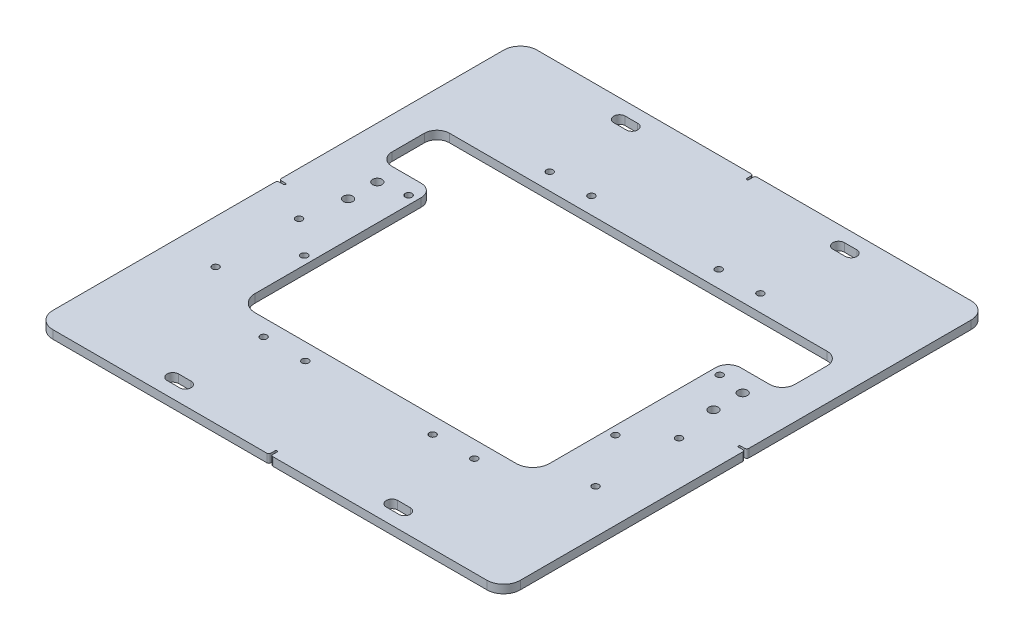
from build123d import *

# Parameters (mm, degrees)
SKETCH2_W               = 355.6
SKETCH2_H               = 368.3
BOSS_EXTRUDE1_DEPTH     = 6.35
FILLET1_R               = 12.7
MOUNTING_HOLES_DEPTH    = 7.35
PLUNGER_CUTOUT_DEPTH    = 7.35
F_1_4_20_TAPPED_HOLE2_D = 5.1054
CENTERING_MARKERS_DEPTH = 7.35
FILLET2_R               = 1.5875
F_1_4_20_TAPPED_HOLE5_D = 5.1054
SKETCH17_R              = 3.571875
CUT_EXTRUDE1_DEPTH      = 7.35


with BuildPart() as part:
    # Sketch2 → Boss-Extrude1 (new body)
    with BuildSketch(Plane(origin=(0, 0, 0), x_dir=(1, 0, 0), z_dir=(0, 1, 0))):
        Rectangle(SKETCH2_W, SKETCH2_H)
    extrude(amount=BOSS_EXTRUDE1_DEPTH)

    # Fillet1
    fillet1_edges = [part.edges().sort_by_distance(p)[0] for p in [
        (177.8, 3.175, 184.15),
        (-177.8, 3.175, 184.15),
        (-177.8, 3.175, -184.15),
        (177.8, 3.175, -184.15),
    ]]
    fillet(fillet1_edges, radius=FILLET1_R)

    # Sketch3 → MOUNTING HOLES (cut, through all)
    with BuildSketch(Plane(origin=(0, 6.35, 0), x_dir=(1, 0, 0), z_dir=(0, 1, 0))):
        with BuildLine():
            Line((-88.10625, 174.228125), (-78.58125, 174.228125))
            ThreePointArc((-78.58125, 174.228125), (-74.215625, 169.8625), (-78.58125, 165.496875))
            Line((-78.58125, 165.496875), (-88.10625, 165.496875))
            ThreePointArc((-88.10625, 165.496875), (-92.471875, 169.8625), (-88.10625, 174.228125))
        make_face()
        with BuildLine():
            Line((88.10625, 165.496875), (78.58125, 165.496875))
            ThreePointArc((78.58125, 165.496875), (74.215625, 169.8625), (78.58125, 174.228125))
            Line((78.58125, 174.228125), (88.10625, 174.228125))
            ThreePointArc((88.10625, 174.228125), (92.471875, 169.8625), (88.10625, 165.496875))
        make_face()
        with BuildLine():
            Line((-88.10625, -165.496875), (-78.58125, -165.496875))
            ThreePointArc((-78.58125, -165.496875), (-74.215625, -169.8625), (-78.58125, -174.228125))
            Line((-78.58125, -174.228125), (-88.10625, -174.228125))
            ThreePointArc((-88.10625, -174.228125), (-92.471875, -169.8625), (-88.10625, -165.496875))
        make_face()
        with BuildLine():
            Line((78.58125, -165.496875), (88.10625, -165.496875))
            ThreePointArc((88.10625, -165.496875), (92.471875, -169.8625), (88.10625, -174.228125))
            Line((88.10625, -174.228125), (78.58125, -174.228125))
            ThreePointArc((78.58125, -174.228125), (74.215625, -169.8625), (78.58125, -165.496875))
        make_face()
    extrude(amount=-MOUNTING_HOLES_DEPTH, mode=Mode.SUBTRACT)

    # Sketch4 → PLUNGER CUTOUT (cut, through all)
    with BuildSketch(Plane(origin=(0, 6.35, 0), x_dir=(1, 0, 0), z_dir=(0, 1, 0))):
        with BuildLine():
            Line((-99.28098, -96.10598), (99.28098, -96.10598))
            ThreePointArc((99.28098, -96.10598), (108.261236121, -92.386236121), (111.98098, -83.40598))
            Line((111.98098, -83.40598), (111.98098, 42.86885))
            ThreePointArc((111.98098, 42.86885), (114.770787909, 49.604042091), (121.50598, 52.39385))
            Line((121.50598, 52.39385), (143.66875, 52.39385))
            ThreePointArc((143.66875, 52.39385), (150.403942091, 55.183657909), (153.19375, 61.91885))
            Line((153.19375, 61.91885), (153.19375, 86.58098))
            ThreePointArc((153.19375, 86.58098), (150.403942091, 93.316172091), (143.66875, 96.10598))
            Line((143.66875, 96.10598), (-143.66875, 96.10598))
            ThreePointArc((-143.66875, 96.10598), (-150.403942091, 93.316172091), (-153.19375, 86.58098))
            Line((-153.19375, 86.58098), (-153.19375, 61.91885))
            ThreePointArc((-153.19375, 61.91885), (-150.403942091, 55.183657909), (-143.66875, 52.39385))
            Line((-143.66875, 52.39385), (-121.50598, 52.39385))
            ThreePointArc((-121.50598, 52.39385), (-114.770787909, 49.604042091), (-111.98098, 42.86885))
            Line((-111.98098, 42.86885), (-111.98098, -83.40598))
            ThreePointArc((-111.98098, -83.40598), (-108.261236121, -92.386236121), (-99.28098, -96.10598))
        make_face()
    extrude(amount=-PLUNGER_CUTOUT_DEPTH, mode=Mode.SUBTRACT)

    # 1/4-20 Tapped Hole2 (through all)
    with Locations(Plane(origin=(0, 6.35, 0), x_dir=(1, 0, 0), z_dir=(0, 1, 0))):
        with Locations((-80.16748, -108.81868), (-48.41748, -108.81868), (48.41748, -108.81868), (80.16748, -108.81868), (80.16748, 108.81868), (48.41748, 108.81868), (-48.41748, 108.81868), (-80.16748, 108.81868)):
            Hole(F_1_4_20_TAPPED_HOLE2_D / 2)

    # Sketch10 → CENTERING MARKERS (cut, through all)
    with BuildSketch(Plane(origin=(0, 6.35, 0), x_dir=(1, 0, 0), z_dir=(0, 1, 0))):
        with BuildLine():
            Line((-0.79375, -179.3875), (-0.79375, -184.15))
            Line((-0.79375, -184.15), (0.79375, -184.15))
            Line((0.79375, -184.15), (0.79375, -179.3875))
            ThreePointArc((0.79375, -179.3875), (0, -178.59375), (-0.79375, -179.3875))
        make_face()
        with BuildLine():
            Line((-173.0375, 0.79375), (-177.8, 0.79375))
            Line((-177.8, 0.79375), (-177.8, -0.79375))
            Line((-177.8, -0.79375), (-173.0375, -0.79375))
            ThreePointArc((-173.0375, -0.79375), (-172.24375, 0), (-173.0375, 0.79375))
        make_face()
        with BuildLine():
            Line((173.0375, 0.79375), (177.8, 0.79375))
            Line((177.8, 0.79375), (177.8, -0.79375))
            Line((177.8, -0.79375), (173.0375, -0.79375))
            ThreePointArc((173.0375, -0.79375), (172.24375, 0), (173.0375, 0.79375))
        make_face()
        with BuildLine():
            Line((-0.79375, 179.3875), (-0.79375, 184.15))
            Line((-0.79375, 184.15), (0.79375, 184.15))
            Line((0.79375, 184.15), (0.79375, 179.3875))
            ThreePointArc((0.79375, 179.3875), (0, 178.59375), (-0.79375, 179.3875))
        make_face()
    extrude(amount=-CENTERING_MARKERS_DEPTH, mode=Mode.SUBTRACT)

    # Fillet2
    fillet2_edges = [part.edges().sort_by_distance(p)[0] for p in [
        (177.8, 3.175, -0.79375),
        (177.8, 3.175, 0.79375),
        (0.79375, 3.175, 184.15),
        (-0.79375, 3.175, 184.15),
        (-0.79375, 3.175, -184.15),
        (0.79375, 3.175, -184.15),
        (-177.8, 3.175, 0.79375),
        (-177.8, 3.175, -0.79375),
    ]]
    fillet(fillet2_edges, radius=FILLET2_R)

    # 1/4-20 Tapped Hole5 (through all)
    with Locations(Plane(origin=(0, 6.35, 0), x_dir=(1, 0, 0), z_dir=(0, 1, 0))):
        with Locations((-144.526, -17.4752), (-144.526, -80.9752), (-118.33225, -39.6875), (-118.33225, 39.6875), (118.33225, 39.6875), (118.33225, -39.6875), (144.526, -17.4752), (144.526, -80.9752)):
            Hole(F_1_4_20_TAPPED_HOLE5_D / 2)

    # Sketch17 → Cut-Extrude1 (cut, through all)
    with BuildSketch(Plane(origin=(0, 6.35, 0), x_dir=(1, 0, 0), z_dir=(0, 1, 0))):
        with Locations((-138.96975, 36.5125)):
            Circle(SKETCH17_R)
        with Locations((-138.96975, 14.2875)):
            Circle(SKETCH17_R)
        with Locations((138.96975, 14.2875)):
            Circle(SKETCH17_R)
        with Locations((138.96975, 36.5125)):
            Circle(SKETCH17_R)
    extrude(amount=-CUT_EXTRUDE1_DEPTH, mode=Mode.SUBTRACT)


solid = part.part
